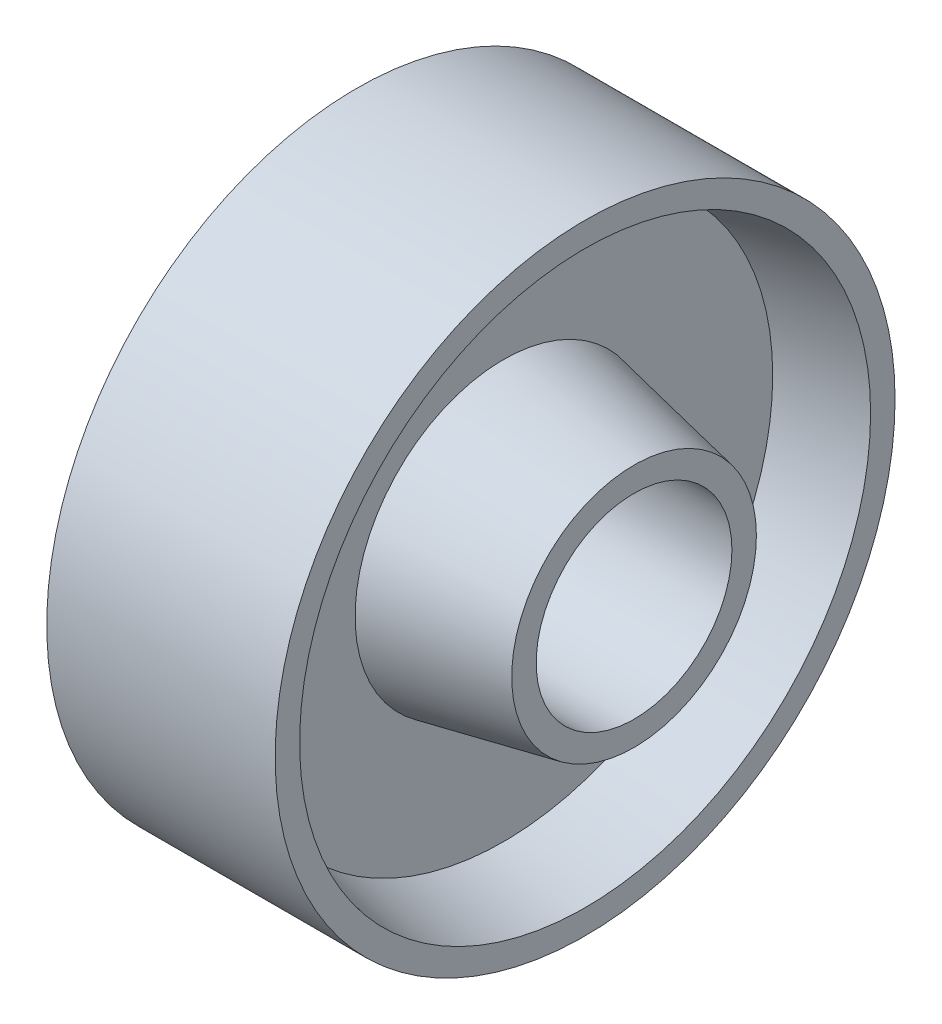
from build123d import *


with BuildPart() as part:
    # Sketch2 → Revolve1 (revolve)
    with BuildSketch(Plane.XY):
        Polygon((20, 15), (20, 12), (-20, 12), (-20, 15), (-4, 18.2), (-4, 33), (-14, 35), (-14, 38), (14, 38), (14, 35), (4, 33), (4, 18.2), align=None)
    revolve(axis=Axis((26.10210505, 0, 0), (-1, 0, 0)))


solid = part.part
